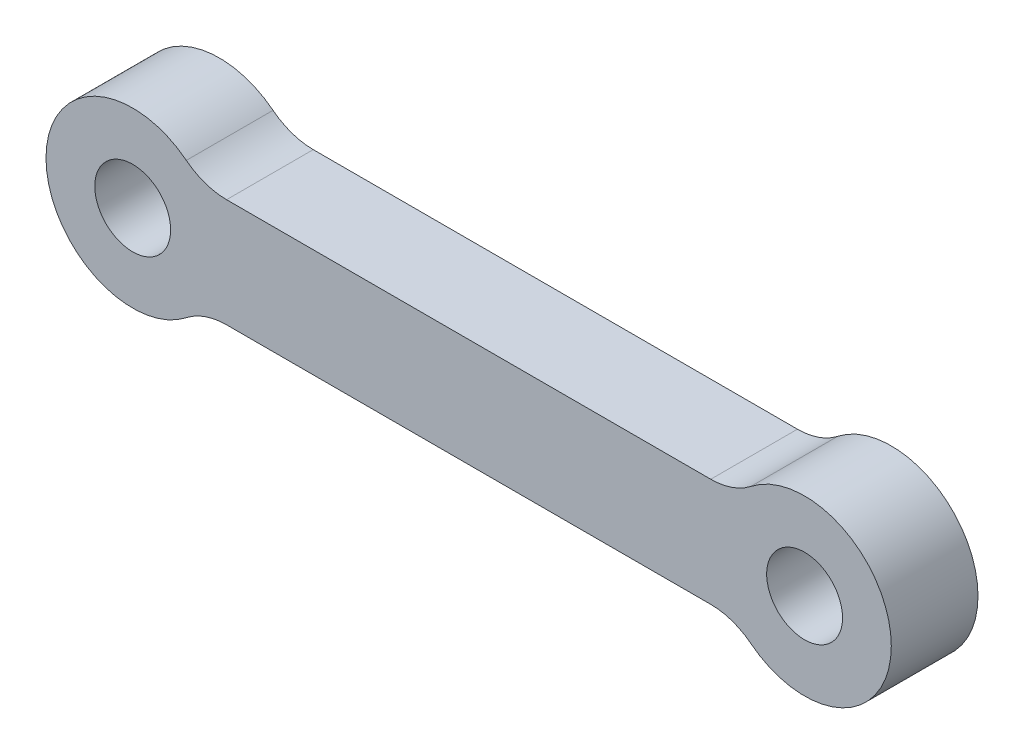
from build123d import *

# Parameters (mm, degrees)
SKETCH1_R           = 1.75
BOSS_EXTRUDE1_DEPTH = 4
FILLET1_R           = 3


with BuildPart() as part:
    # Sketch1 → Boss-Extrude1 (new body)
    with BuildSketch(Plane.XY):
        with BuildLine():
            Line((27.877501001, 2.5), (3.122498999, 2.5))
            ThreePointArc((3.122498999, 2.5), (-4, 0), (3.122498999, -2.5))
            Line((3.122498999, -2.5), (27.877501001, -2.5))
            ThreePointArc((27.877501001, -2.5), (35, 0), (27.877501001, 2.5))
        make_face()
        Circle(SKETCH1_R, mode=Mode.SUBTRACT)
        with Locations((31, 0)):
            Circle(SKETCH1_R, mode=Mode.SUBTRACT)
    extrude(amount=BOSS_EXTRUDE1_DEPTH)

    # Fillet1
    fillet1_edges = [part.edges().sort_by_distance(p)[0] for p in [
        (3.122498999, -2.5, 2),
        (3.122498999, 2.5, 2),
        (27.877501001, 2.5, 2),
        (27.877501001, -2.5, 2),
    ]]
    fillet(fillet1_edges, radius=FILLET1_R)


solid = part.part
